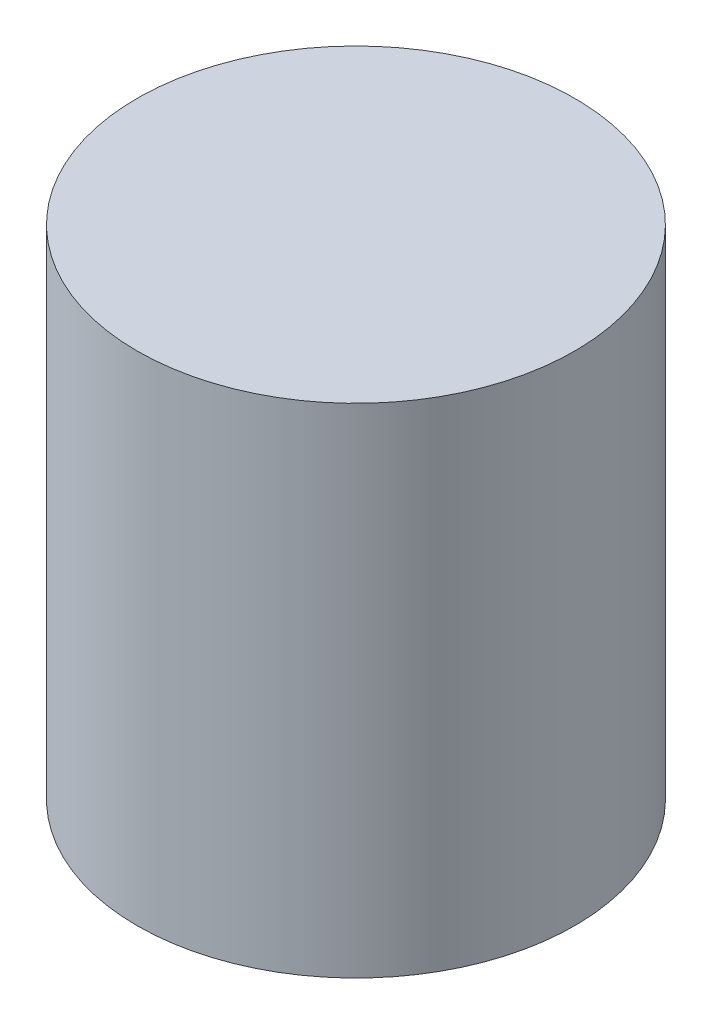
from build123d import *

# Parameters (mm, degrees)
SKETCH1_R           = 25.5
BOSS_EXTRUDE1_DEPTH = 58
SKETCH2_R           = 22.5
CUT_EXTRUDE1_DEPTH  = 55


with BuildPart() as part:
    # Sketch1 → Boss-Extrude1 (new body)
    with BuildSketch(Plane(origin=(0, 0, 0), x_dir=(1, 0, 0), z_dir=(0, 1, 0))):
        with Locations(Location((0, 0, 0), (0, 0, 270))):  # turned: the seam where the file's is
            Circle(SKETCH1_R)
    extrude(amount=BOSS_EXTRUDE1_DEPTH)

    # Sketch2 → Cut-Extrude1 (cut)
    with BuildSketch(Plane.XZ):
        with Locations(Location((0, 0, 0), (0, 0, 270))):  # turned: the seam where the file's is
            Circle(SKETCH2_R)
    extrude(amount=-CUT_EXTRUDE1_DEPTH, mode=Mode.SUBTRACT)


solid = part.part
